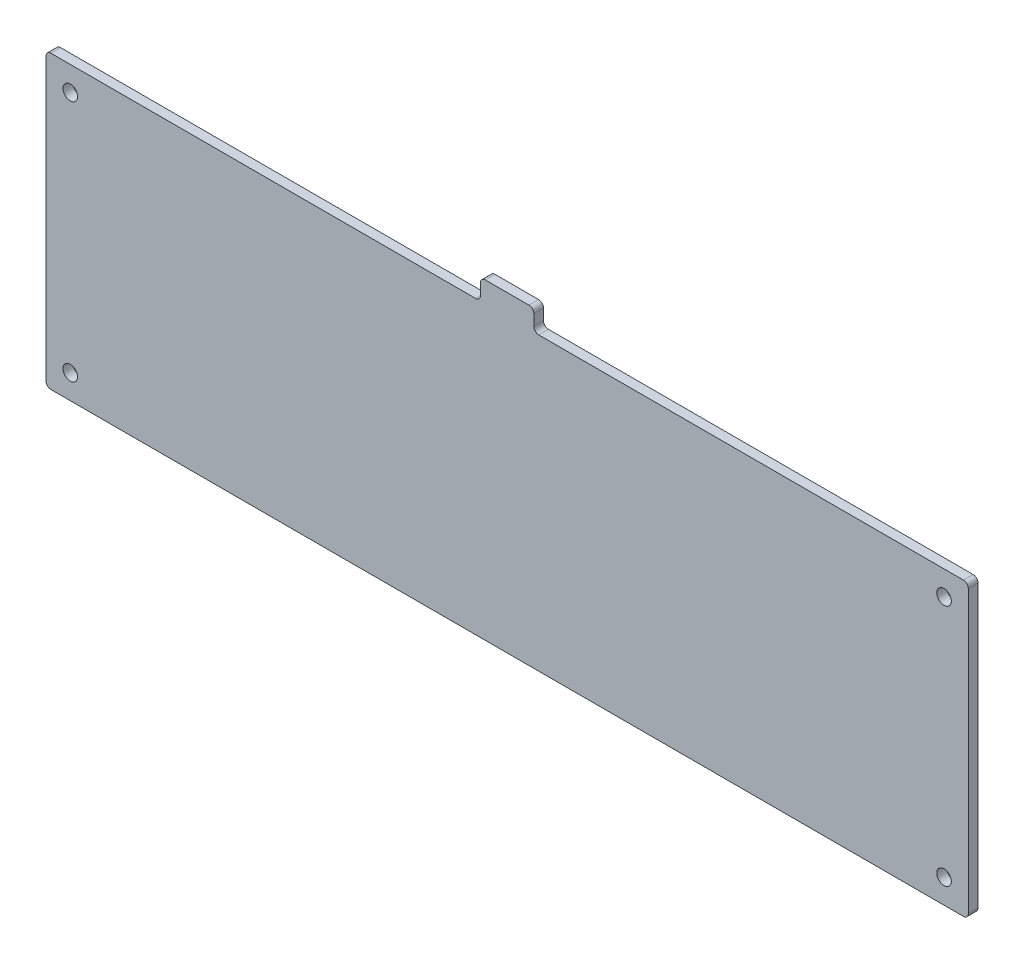
from build123d import *

# Parameters (mm, degrees)
SKETCH_1_R      = 1.5
EXTRUDE_1_DEPTH = 2
FILLET_1_R      = 1


with BuildPart() as part:
    # 草图1 → 凸台-拉伸1 (new body)
    with BuildSketch(Plane.XY):
        Polygon((160, 46.5), (70.5, 46.5), (70.5, 50.8), (59.5, 50.8), (59.5, 46.5), (-30, 46.5), (-30, -13.5), (160, -13.5), align=None)
        with Locations((-25, 41.5)):
            Circle(SKETCH_1_R, mode=Mode.SUBTRACT)
        with Locations((155, 41.5)):
            Circle(SKETCH_1_R, mode=Mode.SUBTRACT)
        with Locations((-25, -8.5)):
            Circle(SKETCH_1_R, mode=Mode.SUBTRACT)
        with Locations((155, -8.5)):
            Circle(SKETCH_1_R, mode=Mode.SUBTRACT)
    extrude(amount=EXTRUDE_1_DEPTH)

    # 圆角1
    fillet_1_edges = [part.edges().sort_by_distance(p)[0] for p in [
        (59.5, 46.5, 1),
        (59.5, 50.8, 1),
        (70.5, 50.8, 1),
        (70.5, 46.5, 1),
        (160, 46.5, 1),
        (160, -13.5, 1),
        (-30, -13.5, 1),
        (-30, 46.5, 1),
    ]]
    fillet(fillet_1_edges, radius=FILLET_1_R)


solid = part.part
